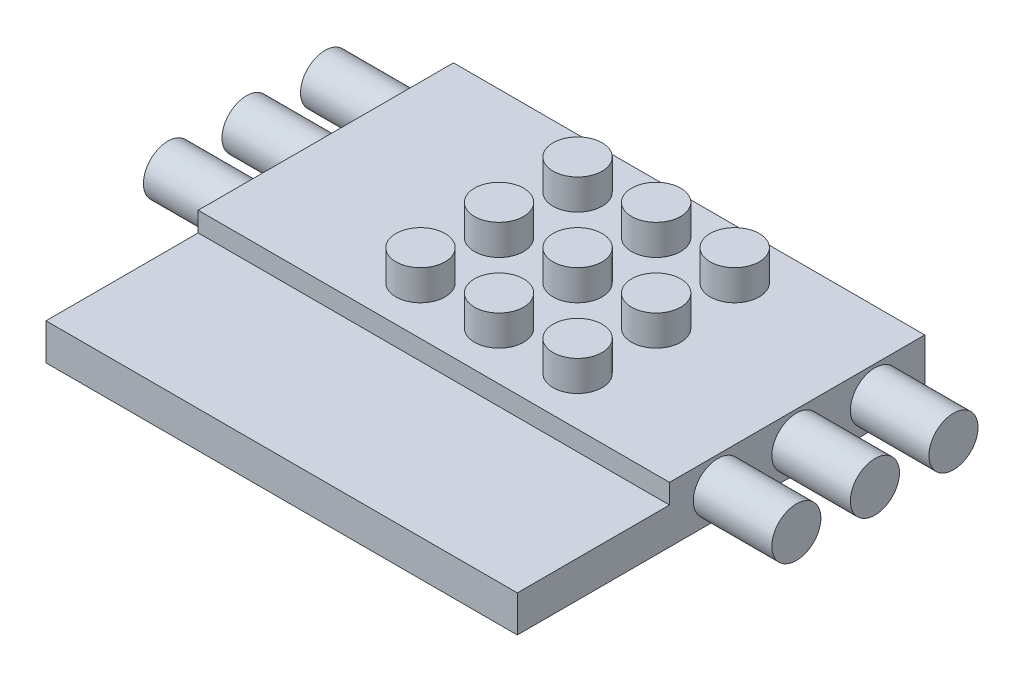
from build123d import *

# Parameters (mm, degrees)
SKETCH3_W                = 6.75
SKETCH3_H                = 10.25
BOSS_EXTRUDE2_DEPTH      = 4.4125
SKETCH5_R                = 1.25
BOSS_EXTRUDE3_DEPTH      = 3.1375
BOSS_EXTRUDE3_DEPTH_BACK = 4.4125
SKETCH6_W                = 20.75
SKETCH6_H                = 2.8575
BOSS_EXTRUDE4_DEPTH      = 6
BOSS_EXTRUDE4_DEPTH_BACK = 18
SKETCH11_W               = 4.903668723
SKETCH11_H               = 13.795083936
CUT_EXTRUDE1_DEPTH       = 4.1425
SKETCH12_W               = 24.809843128
SKETCH12_H               = 8.769619276
CUT_EXTRUDE2_DEPTH       = 1
SKETCH13_R               = 1.25
BOSS_EXTRUDE8_DEPTH      = 4
BOSS_EXTRUDE8_DEPTH_BACK = 28
SKETCH14_W               = 7.412722891
SKETCH14_H               = 4.260464904
CUT_EXTRUDE3_DEPTH       = 1.5
SKETCH15_W               = 10.923147027
SKETCH15_H               = 4.163362597
CUT_EXTRUDE4_DEPTH       = 0.11


with BuildPart() as part:
    # Sketch3 → Boss-Extrude2 (new body)
    with BuildSketch(Plane(origin=(0, 1.5875, 0), x_dir=(-1, 0, 0), z_dir=(0, 1, 0))):
        with Locations((-14.125, -21.125)):
            Rectangle(SKETCH3_W, SKETCH3_H)
    extrude(amount=BOSS_EXTRUDE2_DEPTH)

    # Sketch5 → Boss-Extrude3 (add, two sides)
    with BuildSketch(Plane.XZ.offset(-3.1375)) as boss_extrude3_sk:
        with Locations(Location((16.36, -24.96, 0), (0, 0, 270))):
            Circle(SKETCH5_R)
        with Locations(Location((12.36, -24.96, 0), (0, 0, 270))):
            Circle(SKETCH5_R)
        with Locations(Location((8.36, -24.96, 0), (0, 0, 270))):
            Circle(SKETCH5_R)
        with Locations(Location((16.36, -20.96, 0), (0, 0, 270))):
            Circle(SKETCH5_R)
        with Locations(Location((12.36, -20.96, 0), (0, 0, 270))):
            Circle(SKETCH5_R)
        with Locations(Location((8.36, -20.96, 0), (0, 0, 270))):
            Circle(SKETCH5_R)
        with Locations(Location((16.36, -16.96, 0), (0, 0, 270))):
            Circle(SKETCH5_R)
        with Locations(Location((12.36, -16.96, 0), (0, 0, 270))):
            Circle(SKETCH5_R)
        with Locations(Location((8.36, -16.96, 0), (0, 0, 270))):
            Circle(SKETCH5_R)
    extrude(amount=BOSS_EXTRUDE3_DEPTH)
    extrude(boss_extrude3_sk.sketch, amount=-BOSS_EXTRUDE3_DEPTH_BACK)


with BuildPart() as boss_extrude3_piece_1:
    # of the separate pieces the step leaves, piece 1, a body of its own (boss_extrude3_pieces)
    add(part.part.solids().sort_by_distance((10.75, 1.5875, -16))[0])

    # Sketch6 → Boss-Extrude4 (add, two sides)
    with BuildSketch(Plane(origin=(17.5, 0, 0), x_dir=(0, 0, -1), z_dir=(1, 0, 0))) as boss_extrude4_sk:
        with Locations((17.125, 4.57125)):
            Rectangle(SKETCH6_W, SKETCH6_H)
    extrude(amount=BOSS_EXTRUDE4_DEPTH)
    extrude(boss_extrude4_sk.sketch, amount=-BOSS_EXTRUDE4_DEPTH_BACK)

    # Sketch12 → Cut-Extrude2 (cut)
    with BuildSketch(Plane(origin=(0, 6, 0), x_dir=(1, 0, 0), z_dir=(0, 1, 0))):
        with Locations((11.41674784, 10.115190362)):
            Rectangle(SKETCH12_W, SKETCH12_H)
    extrude(amount=-CUT_EXTRUDE2_DEPTH, mode=Mode.SUBTRACT)

    # Sketch13 → Boss-Extrude8 (add, two sides)
    with BuildSketch(Plane(origin=(23.5, 0, 0), x_dir=(0, 0, -1), z_dir=(1, 0, 0))) as boss_extrude8_sk:
        with Locations((24.96, 4.57125)):
            Circle(SKETCH13_R)
        with Locations((16.96, 4.57125)):
            Circle(SKETCH13_R)
        with Locations((20.96, 4.57125)):
            Circle(SKETCH13_R)
    extrude(amount=BOSS_EXTRUDE8_DEPTH)
    extrude(boss_extrude8_sk.sketch, amount=-BOSS_EXTRUDE8_DEPTH_BACK)

    # Sketch14 → Cut-Extrude3 (cut)
    with BuildSketch(Plane.XY.offset(-16)):
        with Locations((14.456361446, 1.012267548)):
            Rectangle(SKETCH14_W, SKETCH14_H)
    extrude(amount=CUT_EXTRUDE3_DEPTH, mode=Mode.SUBTRACT)

    # Sketch15 → Cut-Extrude4 (cut)
    with BuildSketch(Plane(origin=(17.5, 0, 0), x_dir=(0, 0, -1), z_dir=(1, 0, 0))):
        with Locations((21.461573513, 1.060818702)):
            Rectangle(SKETCH15_W, SKETCH15_H)
    extrude(amount=CUT_EXTRUDE4_DEPTH, mode=Mode.SUBTRACT)


with BuildPart() as boss_extrude3_piece_2:
    # of the separate pieces the step leaves, piece 2, a body of its own (boss_extrude3_pieces)
    add(part.part.solids().sort_by_distance((8.36, 3.1375, -26.21))[0])


with BuildPart() as boss_extrude3_piece_3:
    # of the separate pieces the step leaves, piece 3, a body of its own (boss_extrude3_pieces)
    add(part.part.solids().sort_by_distance((8.36, 3.1375, -22.21))[0])


with BuildPart() as boss_extrude3_piece_4:
    # of the separate pieces the step leaves, piece 4, a body of its own (boss_extrude3_pieces)
    add(part.part.solids().sort_by_distance((8.36, 3.1375, -18.21))[0])


with BuildPart() as cut_extrude1_tool:
    # Sketch11 → Cut-Extrude1 (new body)
    with BuildSketch(Plane.XZ.offset(-3.1425)):
        with Locations((7.758670905, -20.928761162)):
            Rectangle(SKETCH11_W, SKETCH11_H)
    extrude(amount=CUT_EXTRUDE1_DEPTH)


with BuildPart() as boss_extrude3_piece_2_1:
    add(boss_extrude3_piece_2.part)

    # Cut-Extrude1: cut by cut_extrude1_tool
    add(cut_extrude1_tool.part, mode=Mode.SUBTRACT)


with BuildPart() as boss_extrude3_piece_3_1:
    add(boss_extrude3_piece_3.part)

    # Cut-Extrude1: cut by cut_extrude1_tool
    add(cut_extrude1_tool.part, mode=Mode.SUBTRACT)


with BuildPart() as boss_extrude3_piece_4_1:
    add(boss_extrude3_piece_4.part)

    # Cut-Extrude1: cut by cut_extrude1_tool
    add(cut_extrude1_tool.part, mode=Mode.SUBTRACT)


solid = Compound([boss_extrude3_piece_1.part, boss_extrude3_piece_2_1.part, boss_extrude3_piece_3_1.part, boss_extrude3_piece_4_1.part])
